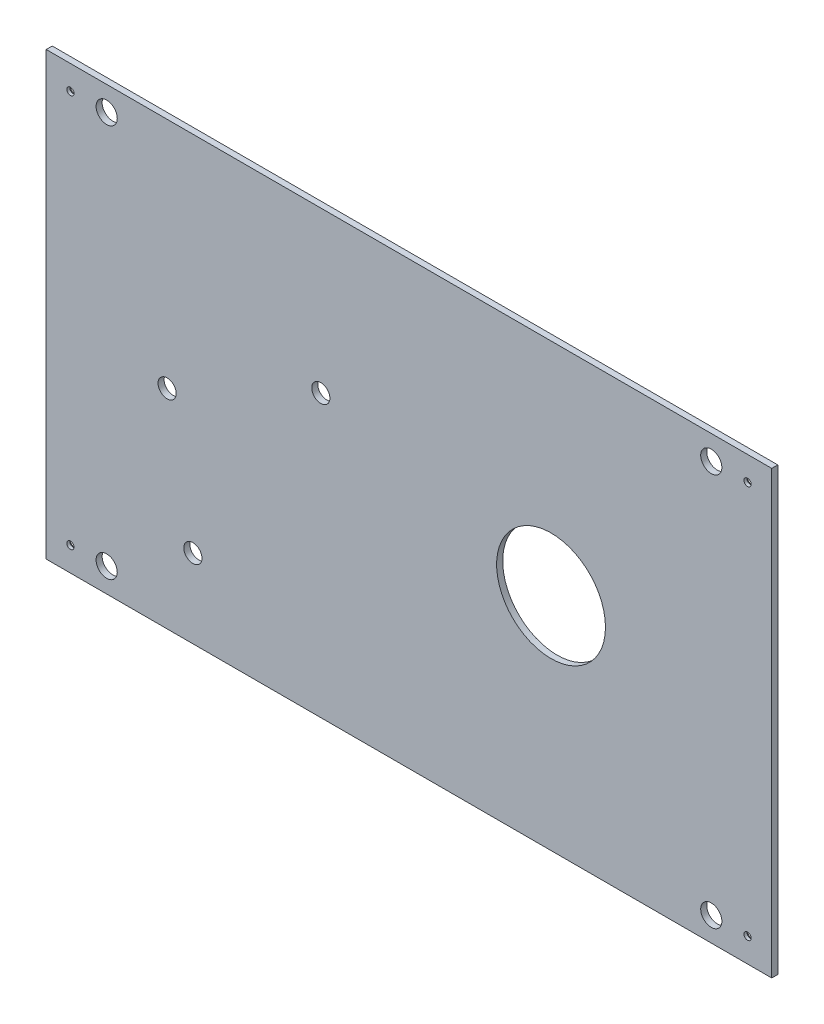
from build123d import *

# Parameters (mm, degrees)
SKETCH_1_W                 = 240
SKETCH_1_H                 = 146
SKETCH_1_R                 = 3
SKETCH_1_R_2               = 18
SKETCH_1_R_3               = 3.5
EXTRUDE_1_DEPTH            = 2
HOLE_WIZARD_M21_AT_2_COUNT = 2
HOLE_WIZARD_M21_AT_2_PITCH = 224
HOLE_WIZARD_M21_AT_3_COUNT = 2
HOLE_WIZARD_M21_AT_3_PITCH = 258.99034731
HOLE_WIZARD_M21_AT_4_COUNT = 2
HOLE_WIZARD_M21_AT_4_PITCH = 130


with BuildPart() as part:
    # Эскиз1 → Бобышка-Вытянуть1 (new body)
    with BuildSketch(Plane.XY):
        with Locations((120, 73)):
            Rectangle(SKETCH_1_W, SKETCH_1_H)
        with Locations((48.515350749, 26)):
            Circle(SKETCH_1_R, mode=Mode.SUBTRACT)
        with Locations((40, 68.913299822)):
            Circle(SKETCH_1_R, mode=Mode.SUBTRACT)
        with Locations((90.832011317, 93)):
            Circle(SKETCH_1_R, mode=Mode.SUBTRACT)
        with Locations((167, 73)):
            Circle(SKETCH_1_R_2, mode=Mode.SUBTRACT)
        with Locations((20, 138)):
            Circle(SKETCH_1_R_3, mode=Mode.SUBTRACT)
        with Locations((20, 8)):
            Circle(SKETCH_1_R_3, mode=Mode.SUBTRACT)
        with Locations((220, 8)):
            Circle(SKETCH_1_R_3, mode=Mode.SUBTRACT)
        with Locations((220, 138)):
            Circle(SKETCH_1_R_3, mode=Mode.SUBTRACT)
    extrude(amount=EXTRUDE_1_DEPTH)

    # Эскиз5 → Зенковка для винта с полупотайной головкой M21 (revolve, cut)
    with BuildSketch(Plane(origin=(232, 138, 0), x_dir=(0, 1, 0), z_dir=(1, 0, 0))):
        Polygon((0, 0), (0, 2), (1.2, 2), (1.2, 1), (2.2, 0), align=None)
    hole_wizard_m21 = revolve(axis=Axis((232, 138, -6.35), (0, 0, 1)), mode=Mode.SUBTRACT)

    # Зенковка для винта с полупотайной головкой M21 at 2: Зенковка для винта с полупотайной головкой M21 ×2
    with Locations(*[(-i * HOLE_WIZARD_M21_AT_2_PITCH, 0, 0) for i in range(1, HOLE_WIZARD_M21_AT_2_COUNT)]):
        add(hole_wizard_m21, mode=Mode.SUBTRACT)

    # Зенковка для винта с полупотайной головкой M21 at 3: Зенковка для винта с полупотайной головкой M21 ×2
    with Locations(*[Vector(-0.864897099, -0.501949209, 0) * (i * HOLE_WIZARD_M21_AT_3_PITCH) for i in range(1, HOLE_WIZARD_M21_AT_3_COUNT)]):
        add(hole_wizard_m21, mode=Mode.SUBTRACT)

    # Зенковка для винта с полупотайной головкой M21 at 4: Зенковка для винта с полупотайной головкой M21 ×2
    with Locations(*[(0, -i * HOLE_WIZARD_M21_AT_4_PITCH, 0) for i in range(1, HOLE_WIZARD_M21_AT_4_COUNT)]):
        add(hole_wizard_m21, mode=Mode.SUBTRACT)


solid = part.part
